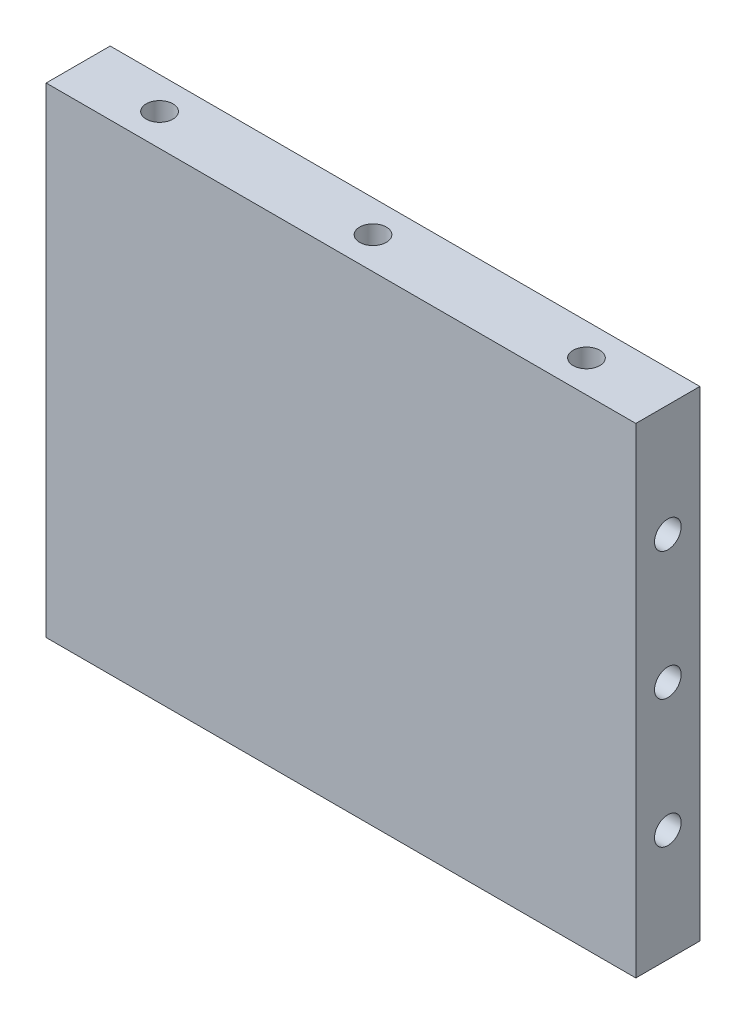
from build123d import *

# Parameters (mm, degrees)
SKETCH_1_W         = 55.25
SKETCH_1_H         = 45
EXTRUDE_1_DEPTH    = 6
HOLE_WIZARD_M3_1_D = 2.5
HOLE_WIZARD_M3_2_D = 2.5


with BuildPart() as part:
    # 草图1 → 凸台-拉伸1 (new body)
    with BuildSketch(Plane.XY):
        Rectangle(SKETCH_1_W, SKETCH_1_H)
    extrude(amount=EXTRUDE_1_DEPTH)

    # M3 螺纹孔1 (through all)
    with Locations(Plane(origin=(0, 22.5, 0), x_dir=(1, 0, 0), z_dir=(0, 1, 0))):
        with Locations((-20, -3), (0, -3), (20, -3)):
            Hole(HOLE_WIZARD_M3_1_D / 2)

    # M3 螺纹孔2 (through all)
    with Locations(Plane.ZY.offset(27.625)):
        with Locations((3, 12), (3, -12), (3, 0)):
            Hole(HOLE_WIZARD_M3_2_D / 2)


solid = part.part
